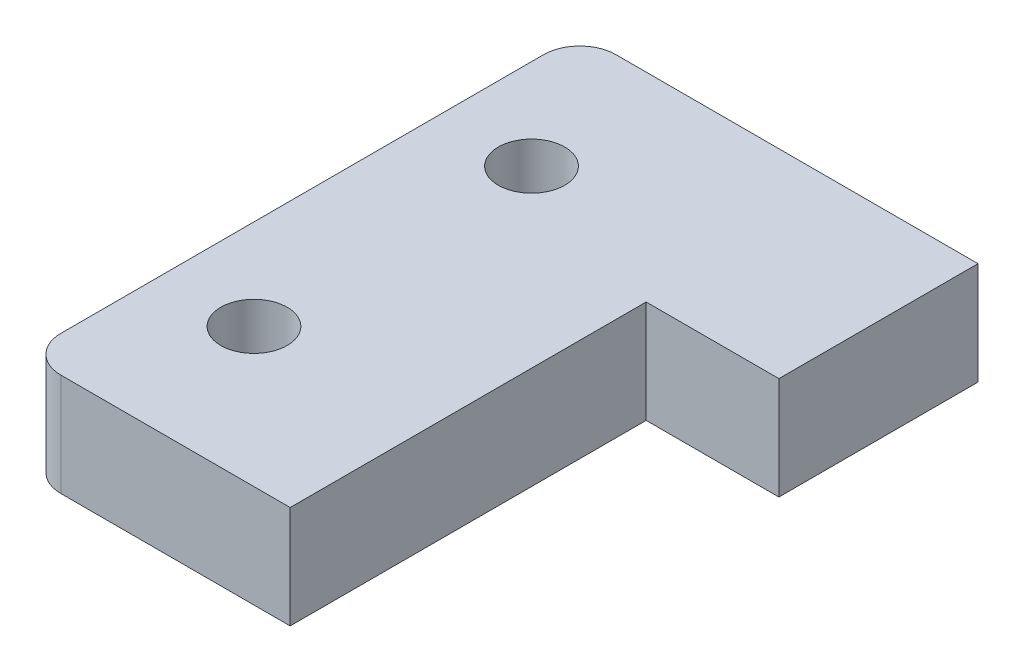
from build123d import *

# Parameters (mm, degrees)
ESBO_O3_R                = 2.75
RESSALTO_EXTRUS_O1_DEPTH = 8.5


with BuildPart() as part:
    # Esboço3 → Ressalto-extrusão1 (new body)
    with BuildSketch(Plane(origin=(0, 0, 0), x_dir=(1, 0, 0), z_dir=(0, 1, 0))):
        with BuildLine():
            Line((-16.5, 20), (-16.5, -20))
            ThreePointArc((-16.5, -20), (-15.621320344, -22.121320344), (-13.5, -23))
            Line((-13.5, -23), (5.5, -23))
            Line((5.5, -23), (5.5, 6.5))
            Line((5.5, 6.5), (16.5, 6.5))
            Line((16.5, 6.5), (16.5, 23))
            Line((16.5, 23), (-13.5, 23))
            ThreePointArc((-13.5, 23), (-15.621320344, 22.121320344), (-16.5, 20))
        make_face()
        with Locations((-9, 11.5)):
            Circle(ESBO_O3_R, mode=Mode.SUBTRACT)
        with Locations((-9, -11.5)):
            Circle(ESBO_O3_R, mode=Mode.SUBTRACT)
    extrude(amount=RESSALTO_EXTRUS_O1_DEPTH)


solid = part.part
